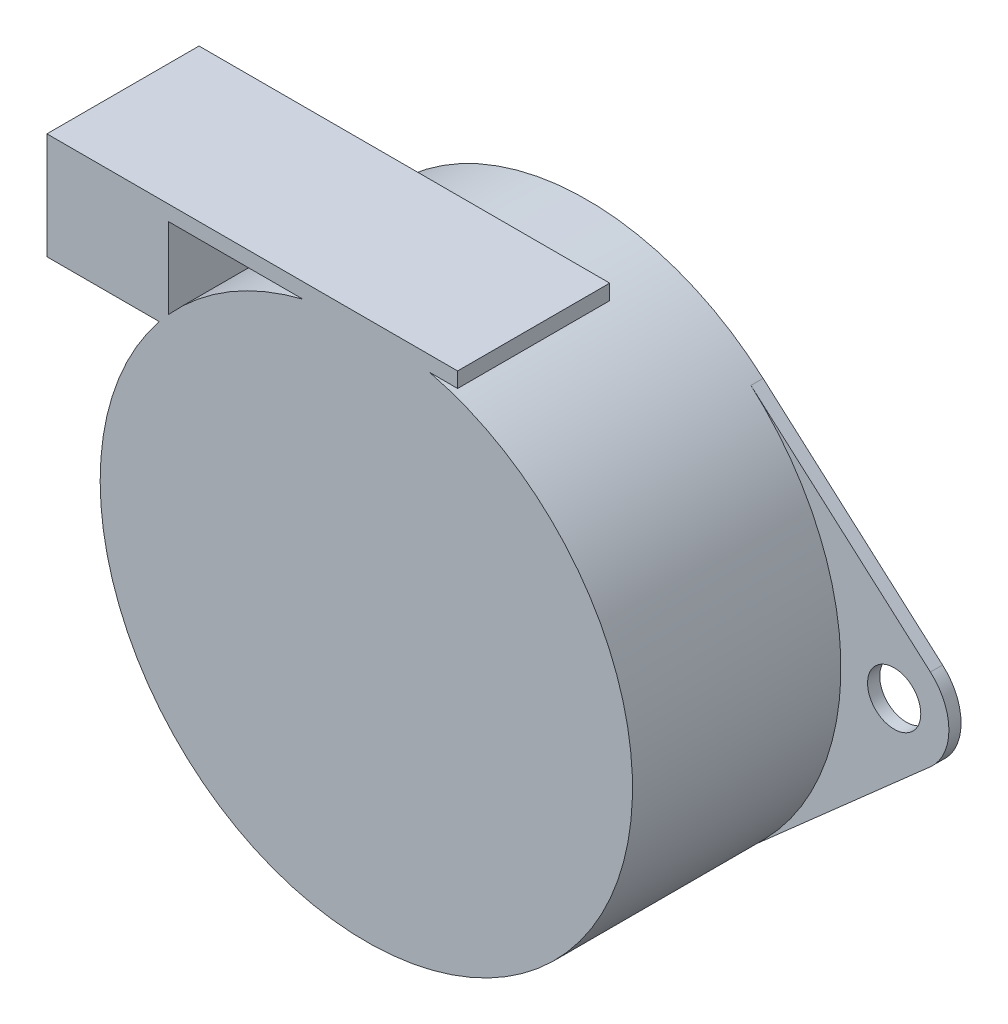
from build123d import *

# Parameters (mm, degrees)
SKETCH_1_R           = 1.75
EXTRUDE_1_DEPTH      = 0.8
SKETCH_2_R           = 17.5
EXTRUDE_2_DEPTH      = 13.7
SKETCH_3_R           = 5
EXTRUDE_3_DEPTH      = 1.5
SKETCH_4_R           = 1
EXTRUDE_4_DEPTH      = 6
EXTRUDE_5_DEPTH      = 0.5
EXTRUDE_5_DEPTH_BACK = 0.5
SKETCH_6_W           = 27
SKETCH_6_H           = 10
SKETCH_7_W           = 8
SKETCH_7_H           = 10
EXTRUDE_6_DEPTH      = 6


with BuildPart() as part:
    # Эскиз1 → Бобышка-Вытянуть1 (new body)
    with BuildSketch(Plane.XY):
        with BuildLine():
            ThreePointArc((11.583333333, 13.117789024), (0, 17.5), (-11.583333333, 13.117789024))
            Line((-11.583333333, 13.117789024), (-23.382857143, 2.698516599))
            ThreePointArc((-23.382857143, 2.698516599), (-24.6, 0), (-23.382857143, -2.698516599))
            Line((-23.382857143, -2.698516599), (-11.583333333, -13.117789024))
            ThreePointArc((-11.583333333, -13.117789024), (0, -17.5), (11.583333333, -13.117789024))
            Line((11.583333333, -13.117789024), (23.382857143, -2.698516599))
            ThreePointArc((23.382857143, -2.698516599), (24.6, 0), (23.382857143, 2.698516599))
            Line((23.382857143, 2.698516599), (11.583333333, 13.117789024))
        make_face()
        with Locations((-21, 0)):
            Circle(SKETCH_1_R, mode=Mode.SUBTRACT)
        with Locations((21, 0)):
            Circle(SKETCH_1_R, mode=Mode.SUBTRACT)
    extrude(amount=EXTRUDE_1_DEPTH)

    # Эскиз2 → Бобышка-Вытянуть2 (add)
    with BuildSketch(Plane.XY.offset(0.8)):
        Circle(SKETCH_2_R)
    extrude(amount=EXTRUDE_2_DEPTH)

    # Эскиз3 → Бобышка-Вытянуть3 (add)
    with BuildSketch(Plane(origin=(0, 0, 0), x_dir=(-1, 0, 0), z_dir=(0, 0, -1))):
        Circle(SKETCH_3_R)
    extrude(amount=EXTRUDE_3_DEPTH)

    # Эскиз4 → Бобышка-Вытянуть4 (add)
    with BuildSketch(Plane(origin=(0, 0, -1.5), x_dir=(-1, 0, 0), z_dir=(0, 0, -1))):
        Circle(SKETCH_4_R)
    extrude(amount=EXTRUDE_4_DEPTH)



with BuildPart() as body_2:
    # Эскиз6 → Бобышка-Вытянуть5 (new, two sides: drawn at the far end of the back side and taken through both)
    with BuildSketch(Plane(origin=(0, 17.5, 0), x_dir=(1, 0, 0), z_dir=(0, 1, 0)).offset(-EXTRUDE_5_DEPTH_BACK)):
        with Locations((-7.5, -9.5)):
            Rectangle(SKETCH_6_W, SKETCH_6_H)
    extrude(amount=EXTRUDE_5_DEPTH + EXTRUDE_5_DEPTH_BACK)


with BuildPart() as part_1:
    add(part.part)

    add(body_2.part)  # Бобышка-Вытянуть6 merges body 2
    # Эскиз7 → Бобышка-Вытянуть6 (add)
    with BuildSketch(Plane.XZ.offset(-17)):
        with Locations((-17, 9.5)):
            Rectangle(SKETCH_7_W, SKETCH_7_H)
    extrude(amount=EXTRUDE_6_DEPTH)


solid = part_1.part
